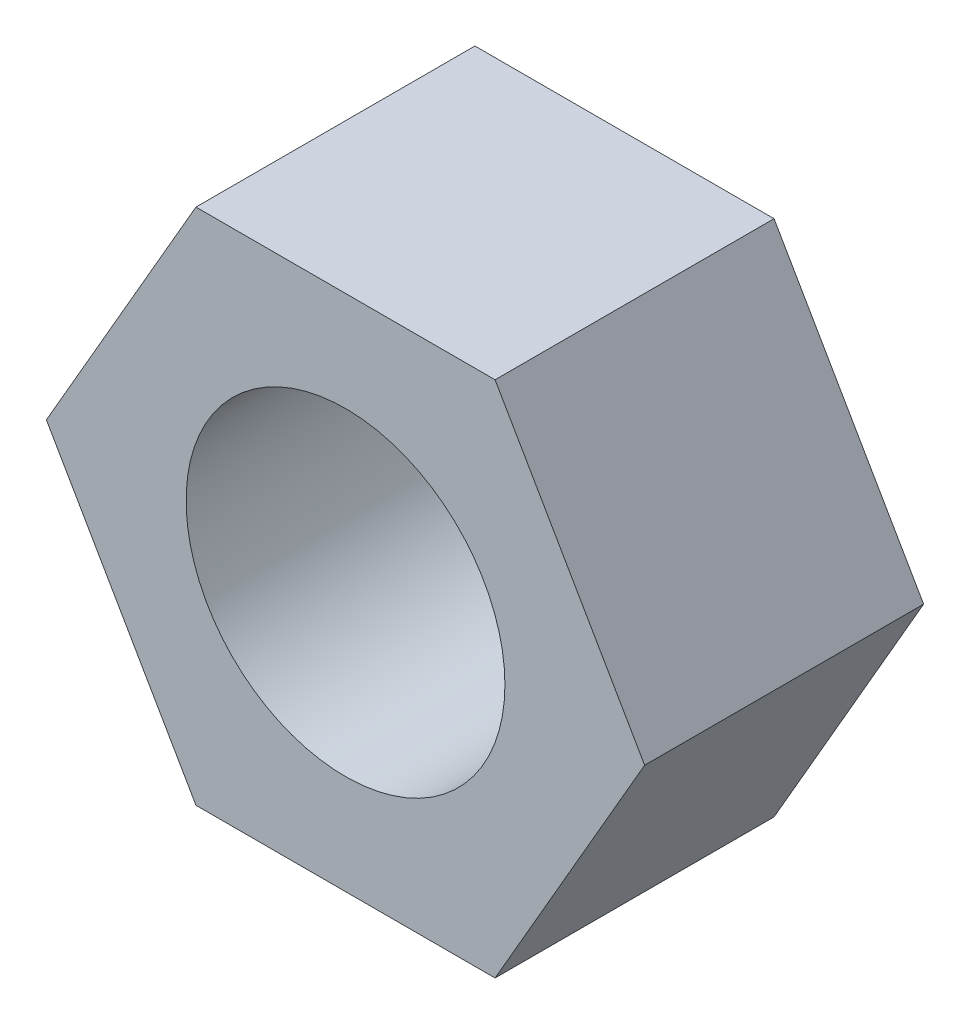
from build123d import *

# Parameters (mm, degrees)
SALIENTE_EXTRUIR1_DEPTH = 7
CROQUIS2_R              = 4
CORTAR_EXTRUIR1_DEPTH   = 8


with BuildPart() as part:
    # Croquis1 → Saliente-Extruir1 (new body)
    with BuildSketch(Plane.XY):
        Polygon((7.505553499, 0), (3.75277675, 6.5), (-3.75277675, 6.5), (-7.505553499, 0), (-3.75277675, -6.5), (3.75277675, -6.5), align=None)
    extrude(amount=SALIENTE_EXTRUIR1_DEPTH)

    # Croquis2 → Cortar-Extruir1 (cut, through all)
    with BuildSketch(Plane.XY.offset(7)):
        Circle(CROQUIS2_R)
    extrude(amount=-CORTAR_EXTRUIR1_DEPTH, mode=Mode.SUBTRACT)


solid = part.part
